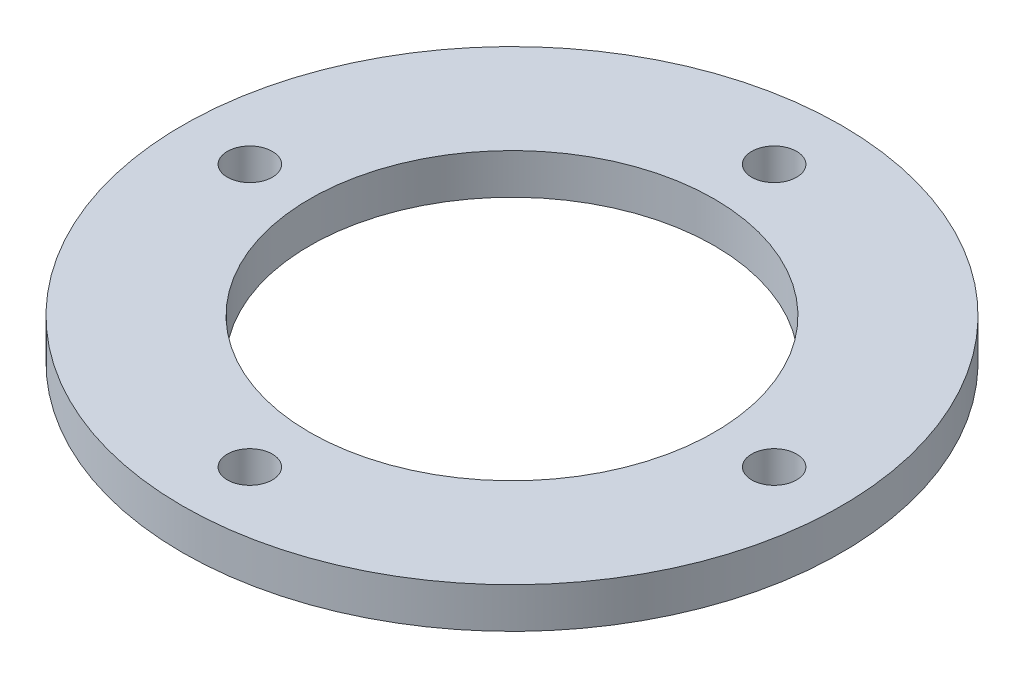
from build123d import *

# Parameters (mm, degrees)
SKETCH_1_R      = 22
SKETCH_1_R_2    = 1.5
SKETCH_1_R_3    = 13.5
EXTRUDE_1_DEPTH = 2.7


with BuildPart() as part:
    # 草图1 → 凸台-拉伸1 (new body)
    with BuildSketch(Plane(origin=(0, 0, 0), x_dir=(1, 0, 0), z_dir=(0, 1, 0))):
        Circle(SKETCH_1_R)
        with Locations((17.5, 0)):
            Circle(SKETCH_1_R_2, mode=Mode.SUBTRACT)
        with Locations((0, -17.5)):
            Circle(SKETCH_1_R_2, mode=Mode.SUBTRACT)
        with Locations((-17.5, 0)):
            Circle(SKETCH_1_R_2, mode=Mode.SUBTRACT)
        with Locations((0, 17.5)):
            Circle(SKETCH_1_R_2, mode=Mode.SUBTRACT)
        Circle(SKETCH_1_R_3, mode=Mode.SUBTRACT)
    extrude(amount=EXTRUDE_1_DEPTH)


solid = part.part
